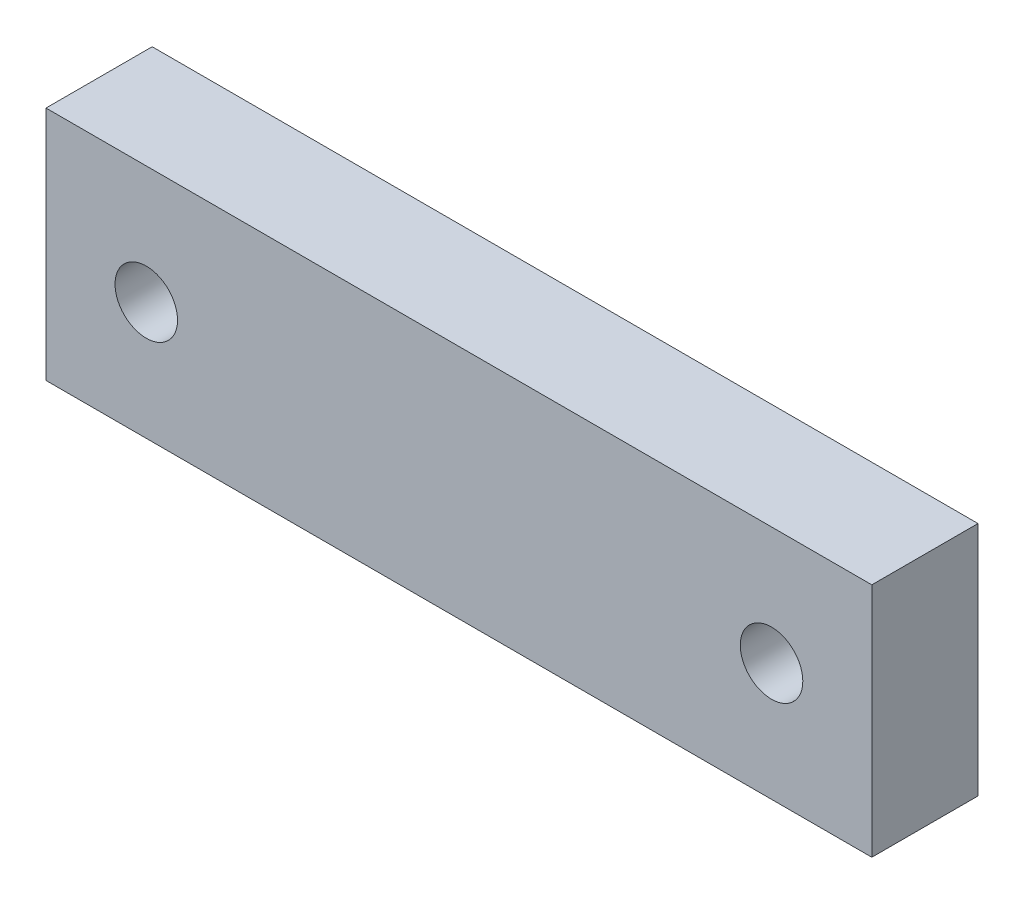
from build123d import *

# Parameters (mm, degrees)
SKETCH1_W      = 70
SKETCH1_H      = 20
SKETCH1_R      = 2.65
EXTRUDE1_DEPTH = 9


with BuildPart() as part:
    # Sketch1 → Extrude1 (new body)
    with BuildSketch(Plane.XY):
        with Locations((0, -52.5)):
            Rectangle(SKETCH1_W, SKETCH1_H)
        with Locations((26.5, -52.5)):
            Circle(SKETCH1_R, mode=Mode.SUBTRACT)
        with Locations((-26.5, -52.5)):
            Circle(SKETCH1_R, mode=Mode.SUBTRACT)
    extrude(amount=EXTRUDE1_DEPTH)


solid = part.part
